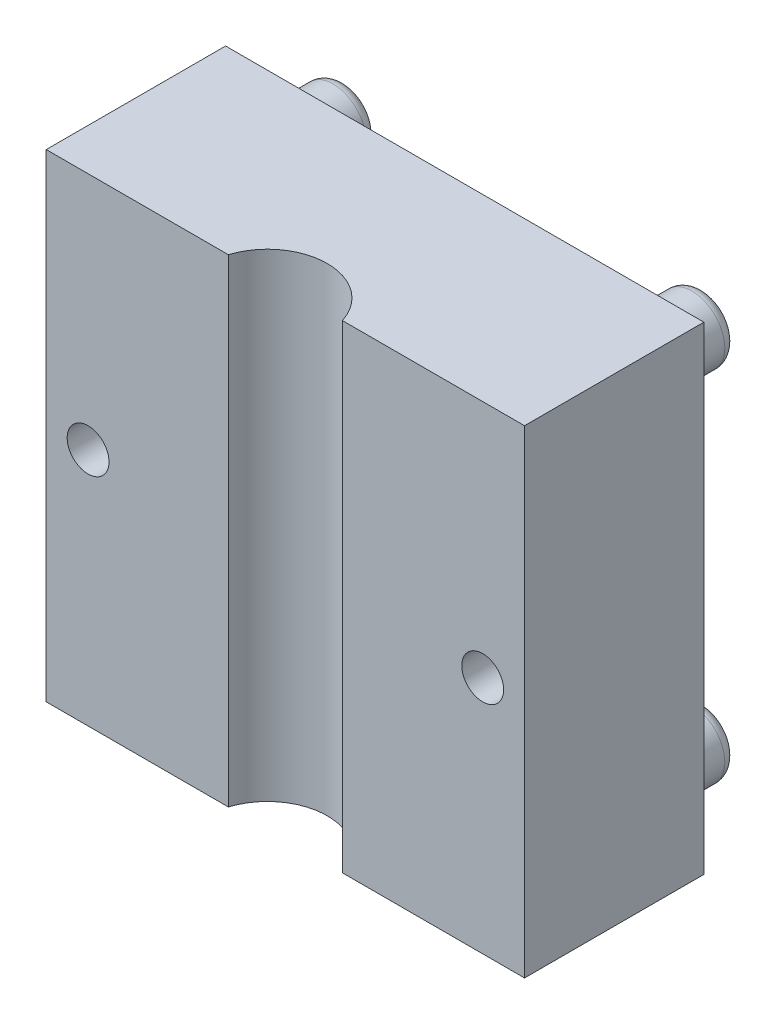
from build123d import *

# Parameters (mm, degrees)
SKETCH1_W           = 40
SKETCH1_H           = 40
BOSS_EXTRUDE1_DEPTH = 15
SKETCH3_R           = 2.75
BOSS_EXTRUDE2_DEPTH = 5
FILLET1_R           = 1
SKETCH4_R           = 12.5
CUT_EXTRUDE1_DEPTH  = 3.5
SKETCH5_R           = 5
CUT_EXTRUDE2_DEPTH  = 41
SKETCH6_R           = 3
CUT_EXTRUDE3_DEPTH  = 2
SKETCH7_R           = 1.75
CUT_EXTRUDE4_DEPTH  = 16


with BuildPart() as part:
    # Sketch1 → Boss-Extrude1 (new body)
    with BuildSketch(Plane.XY):
        Rectangle(SKETCH1_W, SKETCH1_H)
    extrude(amount=BOSS_EXTRUDE1_DEPTH)

    # Sketch3 → Boss-Extrude2 (add)
    with BuildSketch(Plane(origin=(0, 0, 0), x_dir=(-1, 0, 0), z_dir=(0, 0, -1))):
        with Locations(Location((-15, 15, 0), (0, 0, 180))):  # turned: the seam where the file's is
            Circle(SKETCH3_R)
        with Locations(Location((15, 15, 0), (0, 0, 180))):  # turned: the seam where the file's is
            Circle(SKETCH3_R)
        with Locations(Location((-15, -15, 0), (0, 0, 180))):  # turned: the seam where the file's is
            Circle(SKETCH3_R)
        with Locations(Location((15, -15, 0), (0, 0, 180))):  # turned: the seam where the file's is
            Circle(SKETCH3_R)
    extrude(amount=BOSS_EXTRUDE2_DEPTH)

    # Fillet1
    fillet1_edges = [part.edges().sort_by_distance(p)[0] for p in [
        (12.25, 15, -5),
        (-17.75, 15, -5),
        (12.25, -15, -5),
        (-17.75, -15, -5),
    ]]
    fillet(fillet1_edges, radius=FILLET1_R)

    # Sketch4 → Cut-Extrude1 (cut)
    with BuildSketch(Plane(origin=(0, 0, 0), x_dir=(-1, 0, 0), z_dir=(0, 0, -1))):
        Circle(SKETCH4_R)
    extrude(amount=-CUT_EXTRUDE1_DEPTH, mode=Mode.SUBTRACT)

    # Sketch5 → Cut-Extrude2 (cut, through all)
    with BuildSketch(Plane(origin=(0, 20, 0), x_dir=(1, 0, 0), z_dir=(0, 1, 0))):
        with Locations((0, -16.5)):
            Circle(SKETCH5_R)
    extrude(amount=-CUT_EXTRUDE2_DEPTH, mode=Mode.SUBTRACT)

    # Sketch6 → Cut-Extrude3 (cut)
    with BuildSketch(Plane(origin=(0, 0, 0), x_dir=(-1, 0, 0), z_dir=(0, 0, -1))):
        with Locations((-16.5, 0)):
            Circle(SKETCH6_R)
        with Locations((16.5, 0)):
            Circle(SKETCH6_R)
    extrude(amount=-CUT_EXTRUDE3_DEPTH, mode=Mode.SUBTRACT)

    # Sketch7 → Cut-Extrude4 (cut, through all)
    with BuildSketch(Plane(origin=(0, 0, 0), x_dir=(-1, 0, 0), z_dir=(0, 0, -1))):
        with Locations((16.5, 0)):
            Circle(SKETCH7_R)
        with Locations((-16.5, 0)):
            Circle(SKETCH7_R)
    extrude(amount=-CUT_EXTRUDE4_DEPTH, mode=Mode.SUBTRACT)


solid = part.part
